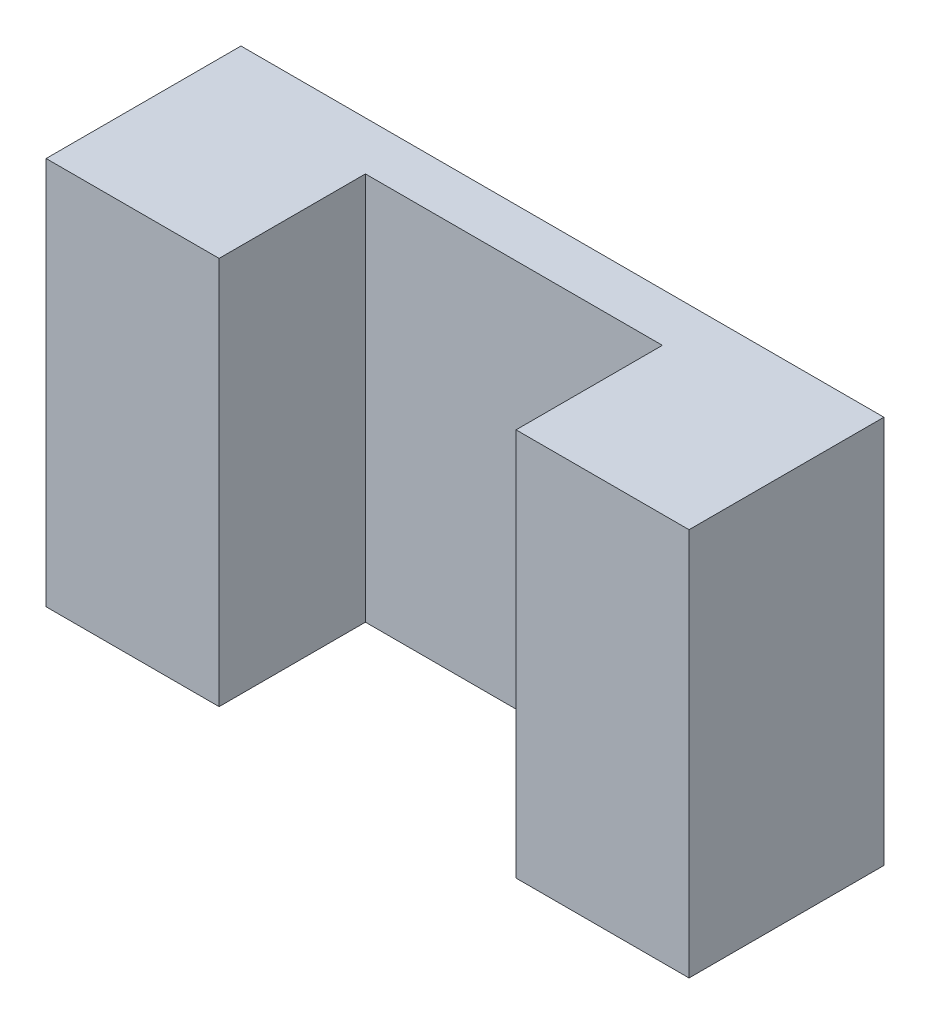
from build123d import *

# Parameters (mm, degrees)
SKETCH1_W           = 65.99377092
SKETCH1_H           = 39.85
BOSS_EXTRUDE1_DEPTH = 20
SKETCH2_W           = 30.48
SKETCH2_H           = 39.85
CUT_EXTRUDE1_DEPTH  = 15.02


with BuildPart() as part:
    # Sketch1 → Boss-Extrude1 (new body)
    with BuildSketch(Plane.XY):
        Rectangle(SKETCH1_W, SKETCH1_H)
    extrude(amount=BOSS_EXTRUDE1_DEPTH)

    # Sketch2 → Cut-Extrude1 (cut)
    with BuildSketch(Plane.XY.offset(20)):
        Rectangle(SKETCH2_W, SKETCH2_H)
    extrude(amount=-CUT_EXTRUDE1_DEPTH, mode=Mode.SUBTRACT)


solid = part.part
